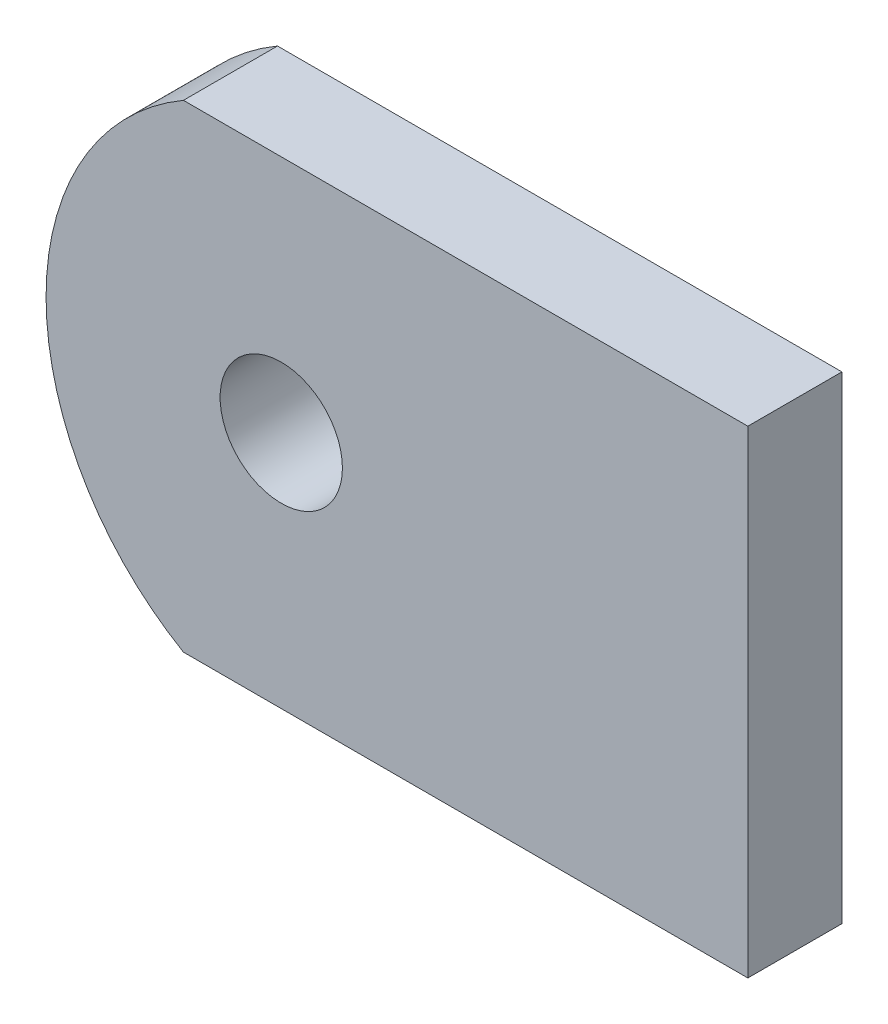
from build123d import *

# Parameters (mm, degrees)
SKETCH2_R           = 3.25
BOSS_EXTRUDE1_DEPTH = 5


with BuildPart() as part:
    # Sketch2 → Boss-Extrude1 (new body)
    with BuildSketch(Plane(origin=(-6.466672358, 0, 0), x_dir=(1, 0, 0), z_dir=(0, 0, 1))):
        with BuildLine():
            Line((-251, 239.45847851), (-281, 239.45847851))
            ThreePointArc((-281, 239.45847851), (-288.3, 226.75847851), (-281, 214.05847851))
            Line((-281, 214.05847851), (-251, 214.05847851))
            Line((-251, 214.05847851), (-251, 239.45847851))
        make_face()
        with Locations((-275.8, 226.75847851)):
            Circle(SKETCH2_R, mode=Mode.SUBTRACT)
    extrude(amount=BOSS_EXTRUDE1_DEPTH)


solid = part.part
